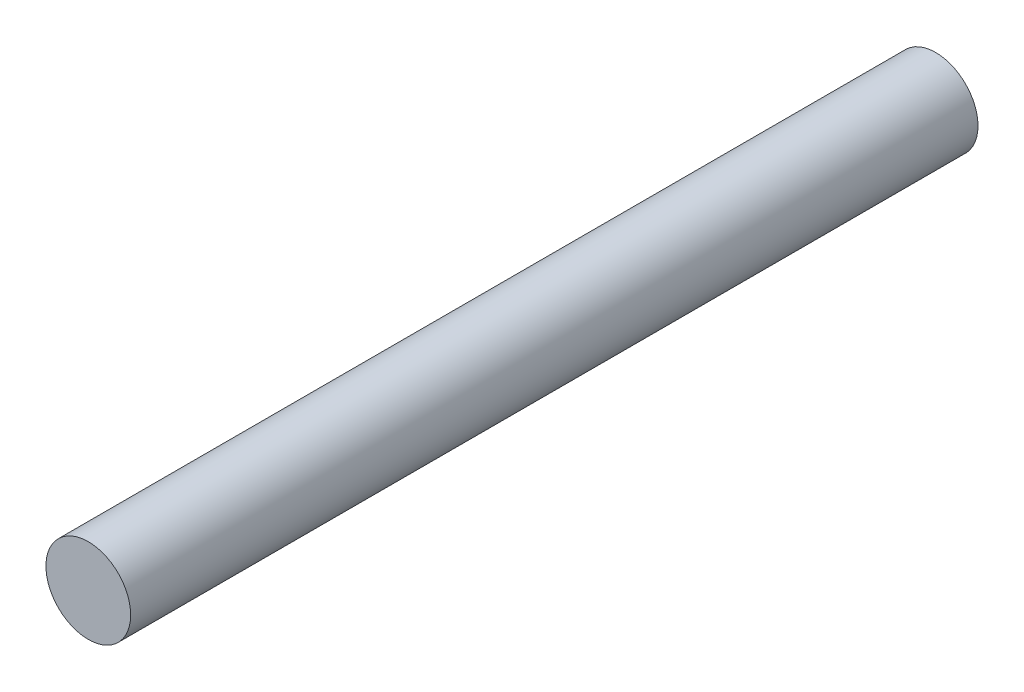
from build123d import *

# Parameters (mm, degrees)
CROQUIS1_R              = 0.6
SALIENTE_EXTRUIR1_DEPTH = 12


with BuildPart() as part:
    # Croquis1 → Saliente-Extruir1 (new body)
    with BuildSketch(Plane.XY):
        Circle(CROQUIS1_R)
    extrude(amount=SALIENTE_EXTRUIR1_DEPTH)


solid = part.part
